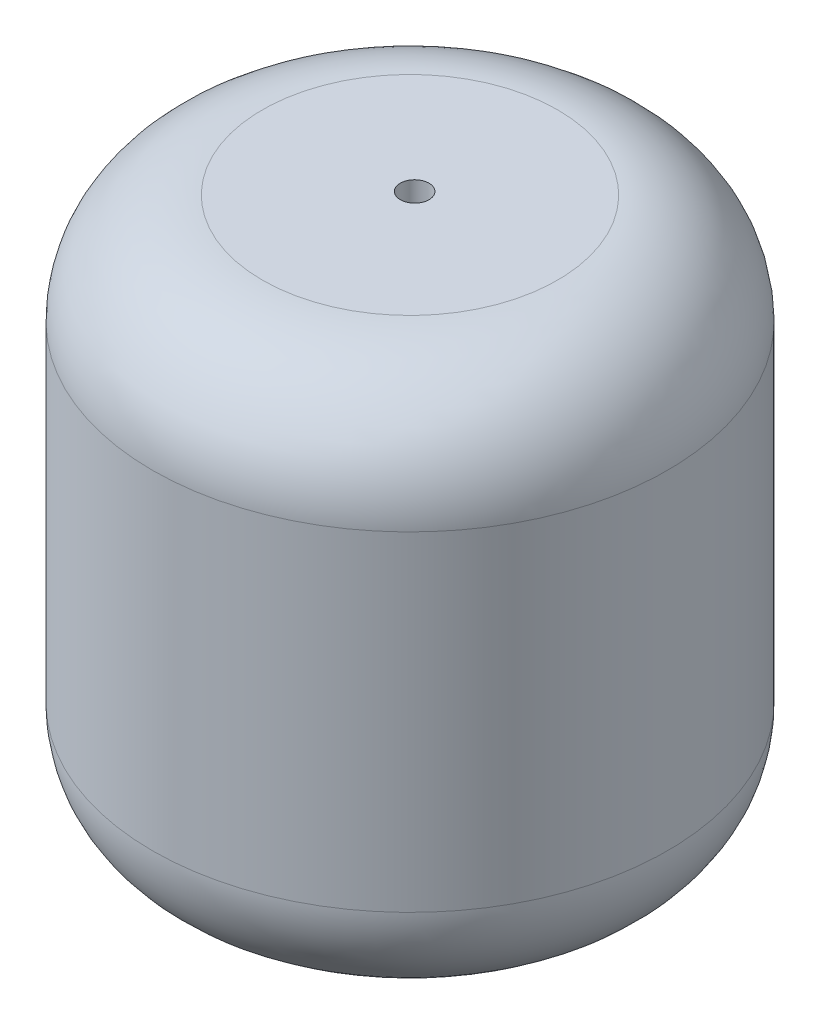
from build123d import *

# Parameters (mm, degrees)
SKETCH1_R           = 11.90625
BOSS_EXTRUDE1_DEPTH = 25.4
FILLET3_R           = 5.08
FILLET4_R           = 5.08
SKETCH2_R           = 0.664162981
CUT_EXTRUDE1_DEPTH  = 25.4


with BuildPart() as part:
    # Sketch1 → Boss-Extrude1 (new body)
    with BuildSketch(Plane(origin=(0, 0, 0), x_dir=(1, 0, 0), z_dir=(0, 1, 0))):
        with Locations((-4.800132003, 11.466982006)):
            Circle(SKETCH1_R)
    extrude(amount=BOSS_EXTRUDE1_DEPTH)

    # Fillet3
    fillet3_edges = [part.edges().sort_by_distance(p)[0] for p in [
        (-16.706382003, 25.4, -11.466982006),
    ]]
    fillet(fillet3_edges, radius=FILLET3_R)

    # Fillet4
    fillet4_edges = [part.edges().sort_by_distance(p)[0] for p in [
        (-16.706382003, 0, -11.466982006),
    ]]
    fillet(fillet4_edges, radius=FILLET4_R)

    # Sketch2 → Cut-Extrude1 (cut)
    with BuildSketch(Plane(origin=(0, 25.4, 0), x_dir=(1, 0, 0), z_dir=(0, 1, 0))):
        with Locations((-4.833340152, 11.716043124)):
            Circle(SKETCH2_R)
    extrude(amount=-CUT_EXTRUDE1_DEPTH, mode=Mode.SUBTRACT)


solid = part.part
